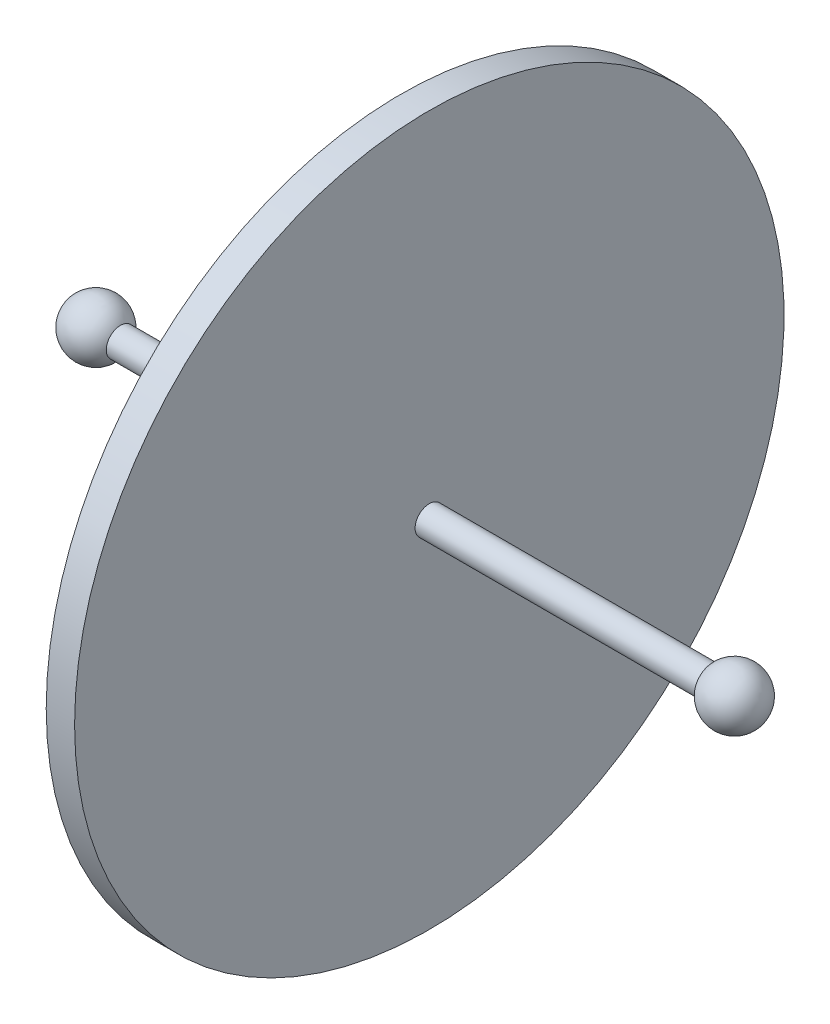
from build123d import *


with BuildPart() as part:
    # Esquisse1 → Révolution1 (revolve)
    with BuildSketch(Plane.XY):
        with BuildLine():
            Line((0, 0), (0, 50))
            Line((0, 50), (2, 50))
            Line((2, 50), (2, 2))
            Line((2, 2), (41.535898385, 2))
            ThreePointArc((41.535898385, 2), (46.03527618, 3.863703305), (49, 0))
            Line((49, 0), (0, 0))
        make_face()
    r_volution1 = revolve(axis=Axis((0, 0, 0), (1, 0, 0)))

    # Symétrie1: Révolution1 across plane
    add(r_volution1.mirror(Plane(origin=(0, 0, 0), x_dir=(0, 0, 1), z_dir=(1, 0, 0))))


solid = part.part
